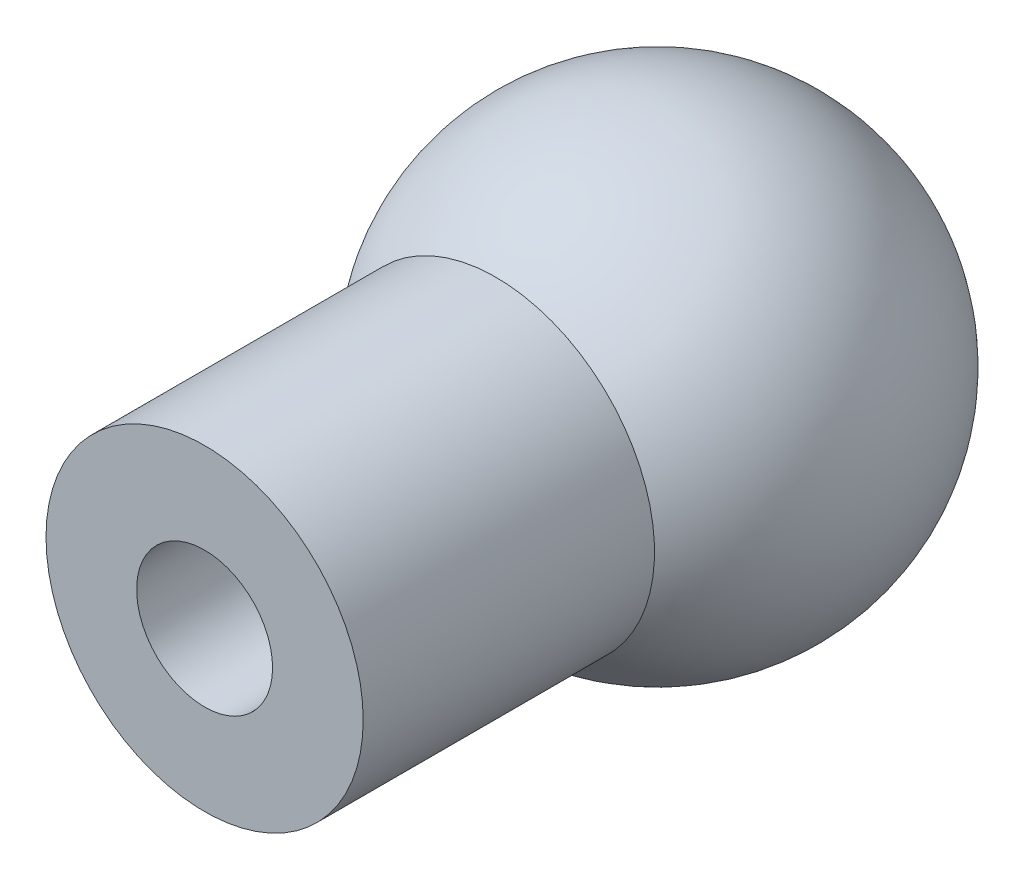
from build123d import *

# Parameters (mm, degrees)
SKETCH2_R           = 1.5
CUT_EXTRUDE1_DEPTH  = 6
SKETCH2_3_R         = 3.5
SKETCH2_3_R_2       = 1.5
BOSS_EXTRUDE1_DEPTH = 10


with BuildPart() as part:
    # Sketch1 → Revolve1 (revolve)
    with BuildSketch(Plane.XY):
        with BuildLine():
            Line((0, 5), (0, -5))
            ThreePointArc((0, -5), (5, 0), (0, 5))
        make_face()
    revolve(axis=Axis((0, 5, 0), (0, -1, 0)))

    # Sketch2 → Cut-Extrude1 (cut, through all)
    with BuildSketch(Plane.XY):
        with Locations(Location((0, 0, 0), (0, 0, 180))):  # turned: the seam where the file's is
            Circle(SKETCH2_R)
    extrude(amount=CUT_EXTRUDE1_DEPTH, mode=Mode.SUBTRACT)

    # Sketch2_3 → Boss-Extrude1 (add)
    with BuildSketch(Plane.XY):
        with Locations(Location((0, 0, 0), (0, 0, 180))):  # turned: the seam where the file's is
            Circle(SKETCH2_3_R)
        Circle(SKETCH2_3_R_2, mode=Mode.SUBTRACT)
    extrude(amount=BOSS_EXTRUDE1_DEPTH)


solid = part.part
